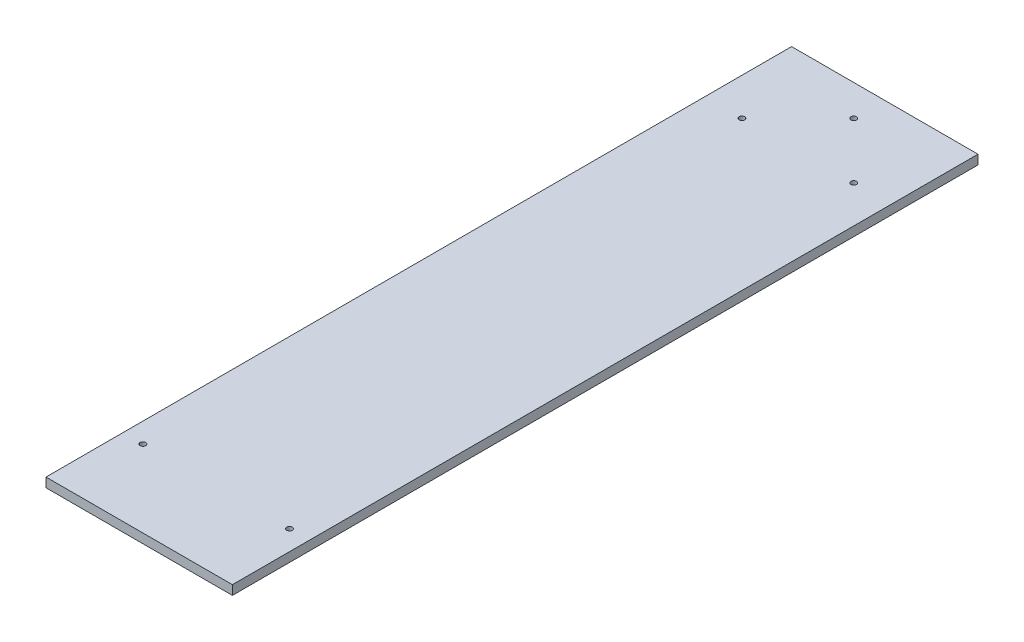
from build123d import *

# Parameters (mm, degrees)
SKETCH1_W           = 300
SKETCH1_H           = 1200
BOSS_EXTRUDE1_DEPTH = 15
SKETCH3_R           = 4.5
CUT_EXTRUDE1_DEPTH  = 16


with BuildPart() as part:
    # Sketch1 → Boss-Extrude1 (new body)
    with BuildSketch(Plane(origin=(0, 0, 0), x_dir=(1, 0, 0), z_dir=(0, 1, 0))):
        Rectangle(SKETCH1_W, SKETCH1_H)
    extrude(amount=BOSS_EXTRUDE1_DEPTH)

    # Sketch3 → Cut-Extrude1 (cut, through all)
    with BuildSketch(Plane(origin=(0, 15, 0), x_dir=(1, 0, 0), z_dir=(0, 1, 0))):
        with Locations((-90, 460)):
            Circle(SKETCH3_R)
        with Locations((90, 460)):
            Circle(SKETCH3_R)
        with Locations((0, 550)):
            Circle(SKETCH3_R)
        with Locations((-118, -476)):
            Circle(SKETCH3_R)
        with Locations((118, -476)):
            Circle(SKETCH3_R)
    extrude(amount=-CUT_EXTRUDE1_DEPTH, mode=Mode.SUBTRACT)


solid = part.part
